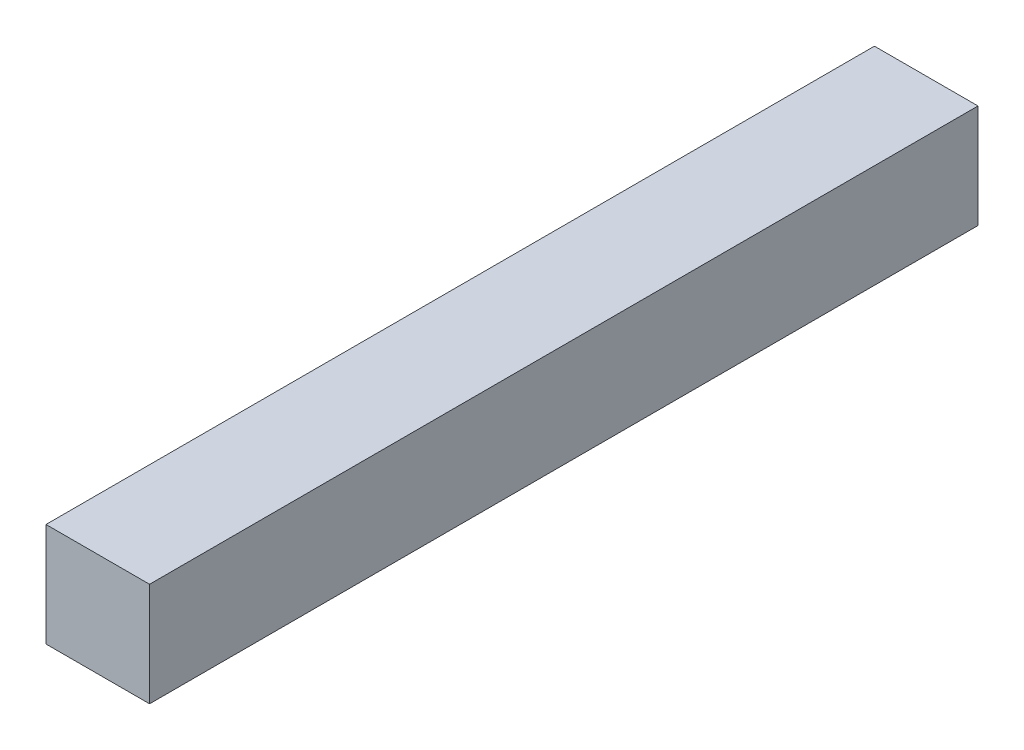
from build123d import *

# Parameters (mm, degrees)
CROQUIS1_W              = 50
CROQUIS1_H              = 50
SALIENTE_EXTRUIR1_DEPTH = 400


with BuildPart() as part:
    # Croquis1 → Saliente-Extruir1 (new body)
    with BuildSketch(Plane.XY):
        with Locations((4.559748428, -2.044025157)):
            Rectangle(CROQUIS1_W, CROQUIS1_H)
    extrude(amount=SALIENTE_EXTRUIR1_DEPTH)


solid = part.part
